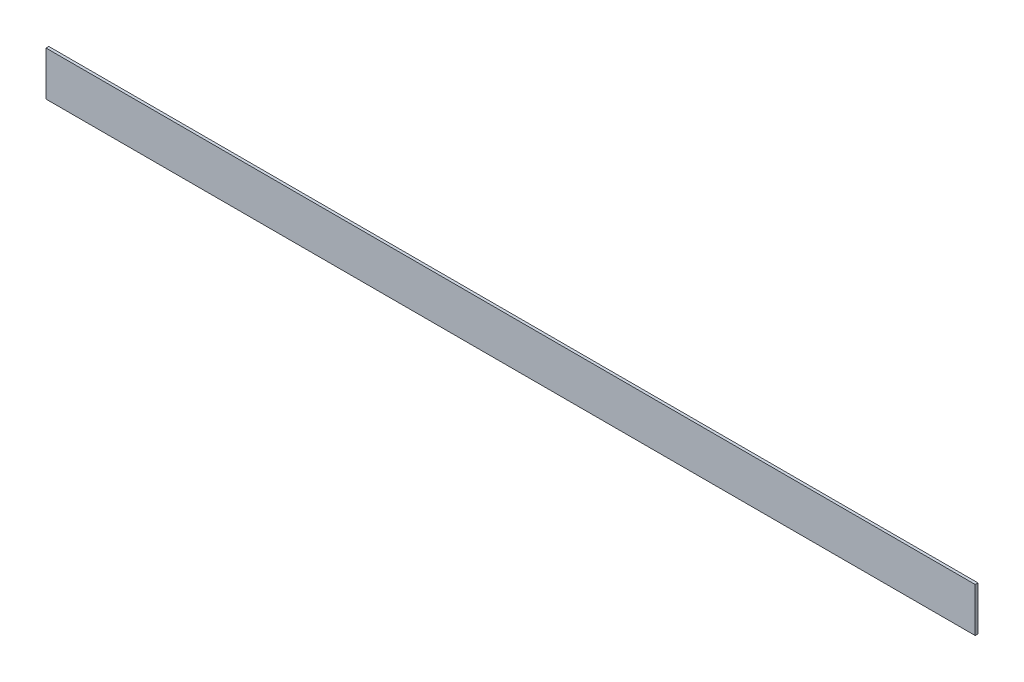
from build123d import *

# Parameters (mm, degrees)
SKETCH1_W           = 1066.8
SKETCH1_H           = 50.8
BOSS_EXTRUDE1_DEPTH = 3.175


with BuildPart() as part:
    # Sketch1 → Boss-Extrude1 (new body)
    with BuildSketch(Plane.XY):
        with Locations((-533.4, -25.4)):
            Rectangle(SKETCH1_W, SKETCH1_H)
    extrude(amount=BOSS_EXTRUDE1_DEPTH)


solid = part.part
